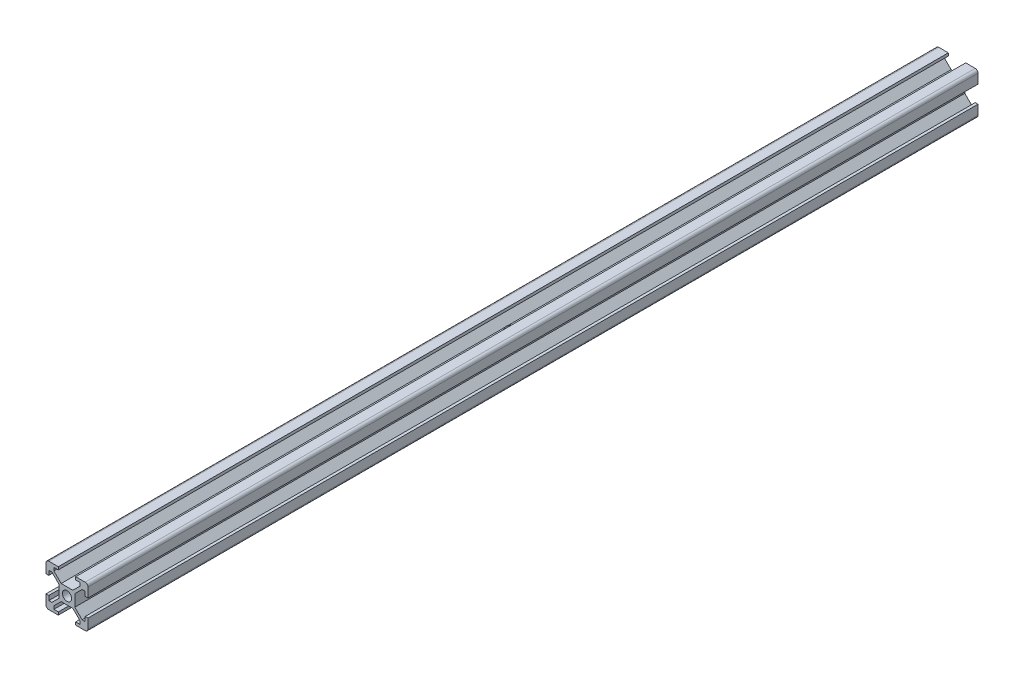
from build123d import *

# Parameters (mm, degrees)
SKETCH_1_R          = 1.65
EXTRUDE_1_DEPTH     = 318
SKETCH_12_R         = 2.15
CUT_EXTRUDE_3_DEPTH = 25


with BuildPart() as part:
    # 草图1 → 凸台-拉伸1 (new body)
    with BuildSketch(Plane.XY):
        with BuildLine():
            Line((-2.092893219, 2.8), (2.092893219, 2.8))
            Line((2.092893219, 2.8), (4.7, 5.407106781))
            Line((4.7, 5.407106781), (4.7, 6.5))
            Line((4.7, 6.5), (3.1, 6.5))
            Line((3.1, 6.5), (3.1, 7.5))
            Line((3.1, 7.5), (6.5, 7.5))
            ThreePointArc((6.5, 7.5), (7.207106781, 7.207106781), (7.5, 6.5))
            Line((7.5, 6.5), (7.5, 3.1))
            Line((7.5, 3.1), (6.5, 3.1))
            Line((6.5, 3.1), (6.5, 4.7))
            Line((6.5, 4.7), (5.407106781, 4.7))
            Line((5.407106781, 4.7), (2.8, 2.092893219))
            Line((2.8, 2.092893219), (2.8, -2.092893219))
            Line((2.8, -2.092893219), (5.407106781, -4.7))
            Line((5.407106781, -4.7), (6.5, -4.7))
            Line((6.5, -4.7), (6.5, -3.1))
            Line((6.5, -3.1), (7.5, -3.1))
            Line((7.5, -3.1), (7.5, -6.5))
            ThreePointArc((7.5, -6.5), (7.207106781, -7.207106781), (6.5, -7.5))
            Line((6.5, -7.5), (3.1, -7.5))
            Line((3.1, -7.5), (3.1, -6.5))
            Line((3.1, -6.5), (4.7, -6.5))
            Line((4.7, -6.5), (4.7, -5.407106781))
            Line((4.7, -5.407106781), (2.092893219, -2.8))
            Line((2.092893219, -2.8), (-2.092893219, -2.8))
            Line((-2.092893219, -2.8), (-4.7, -5.407106781))
            Line((-4.7, -5.407106781), (-4.7, -6.5))
            Line((-4.7, -6.5), (-3.1, -6.5))
            Line((-3.1, -6.5), (-3.1, -7.5))
            Line((-3.1, -7.5), (-6.5, -7.5))
            ThreePointArc((-6.5, -7.5), (-7.207106781, -7.207106781), (-7.5, -6.5))
            Line((-7.5, -6.5), (-7.5, -3.1))
            Line((-7.5, -3.1), (-6.5, -3.1))
            Line((-6.5, -3.1), (-6.5, -4.7))
            Line((-6.5, -4.7), (-5.407106781, -4.7))
            Line((-5.407106781, -4.7), (-2.8, -2.092893219))
            Line((-2.8, -2.092893219), (-2.8, 2.092893219))
            Line((-2.8, 2.092893219), (-5.407106781, 4.7))
            Line((-5.407106781, 4.7), (-6.5, 4.7))
            Line((-6.5, 4.7), (-6.5, 3.1))
            Line((-6.5, 3.1), (-7.5, 3.1))
            Line((-7.5, 3.1), (-7.5, 6.5))
            ThreePointArc((-7.5, 6.5), (-7.207106781, 7.207106781), (-6.5, 7.5))
            Line((-6.5, 7.5), (-3.1, 7.5))
            Line((-3.1, 7.5), (-3.1, 6.5))
            Line((-3.1, 6.5), (-4.7, 6.5))
            Line((-4.7, 6.5), (-4.7, 5.407106781))
            Line((-4.7, 5.407106781), (-2.092893219, 2.8))
        make_face()
        Circle(SKETCH_1_R, mode=Mode.SUBTRACT)
    extrude(amount=EXTRUDE_1_DEPTH)

    # 草图12 → 切除-拉伸3 (cut, symmetric)
    with BuildSketch(Plane(origin=(0, 0, 0), x_dir=(1, 0, 0), z_dir=(0, 1, 0))):
        with Locations((0, -159)):
            Circle(SKETCH_12_R)
    extrude(amount=CUT_EXTRUDE_3_DEPTH, both=True, mode=Mode.SUBTRACT)


solid = part.part
